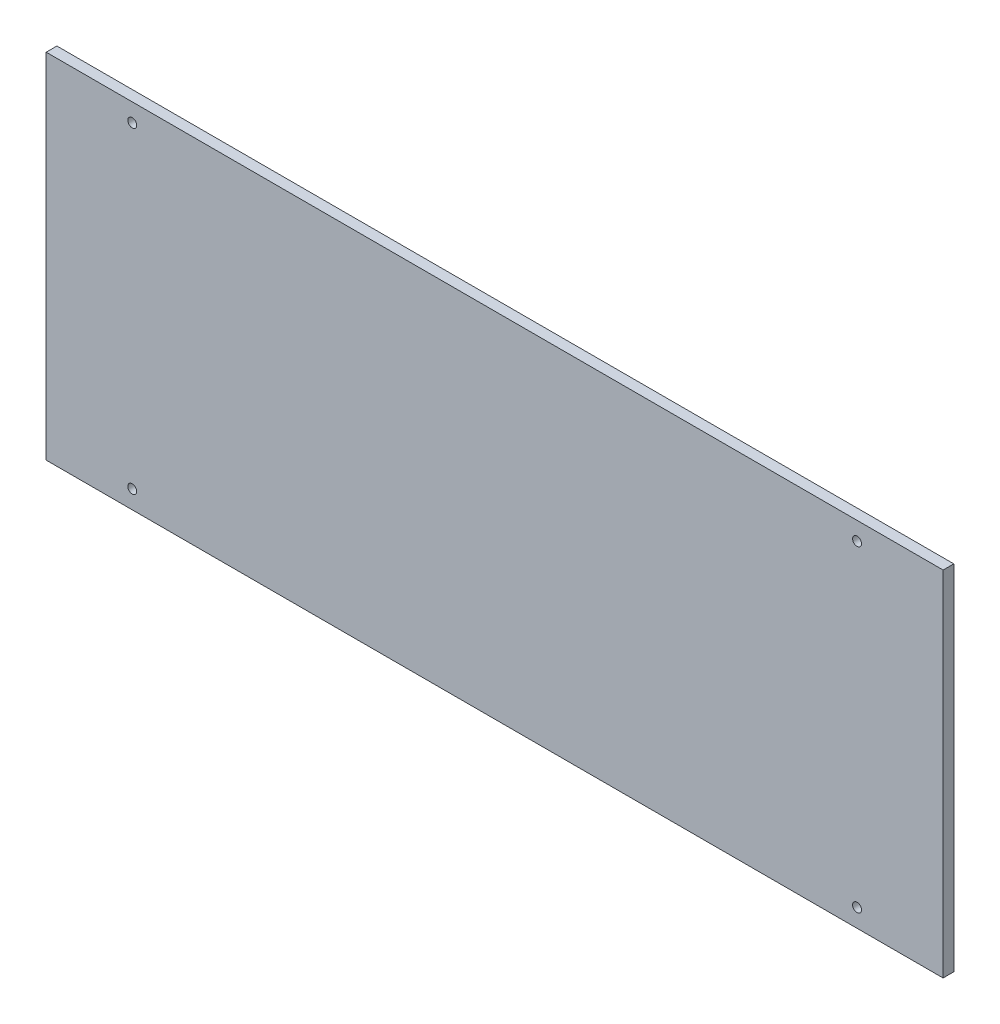
from build123d import *

# Parameters (mm, degrees)
SKETCH1_W           = 251.46
SKETCH1_H           = 99.06
SKETCH1_R           = 1.25
BOSS_EXTRUDE1_DEPTH = 3


with BuildPart() as part:
    # Sketch1 → Boss-Extrude1 (new body)
    with BuildSketch(Plane.XY):
        Rectangle(SKETCH1_W, SKETCH1_H)
        with Locations((-101.6, 44.45)):
            Circle(SKETCH1_R, mode=Mode.SUBTRACT)
        with Locations((101.6, 44.45)):
            Circle(SKETCH1_R, mode=Mode.SUBTRACT)
        with Locations((101.6, -44.45)):
            Circle(SKETCH1_R, mode=Mode.SUBTRACT)
        with Locations((-101.6, -44.45)):
            Circle(SKETCH1_R, mode=Mode.SUBTRACT)
    extrude(amount=BOSS_EXTRUDE1_DEPTH)


solid = part.part
